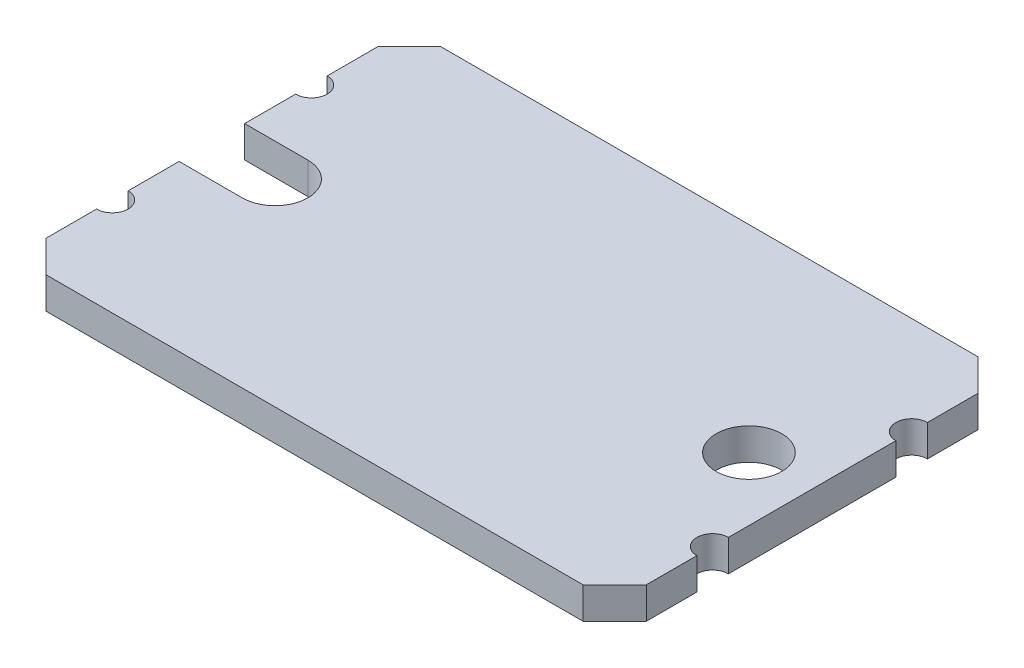
from build123d import *

# Parameters (mm, degrees)
SKETCH1_R      = 2.075
EXTRUDE1_DEPTH = 2


with BuildPart() as part:
    # Sketch1 → Extrude1 (new body)
    with BuildSketch(Plane(origin=(0, 0, 0), x_dir=(1, 0, 0), z_dir=(0, 1, 0))):
        with BuildLine():
            Line((2, 0), (36, 0))
            Line((36, 0), (38, 2))
            Line((38, 2), (38, 5.2))
            ThreePointArc((38, 5.2), (37, 6.2), (38, 7.2))
            Line((38, 7.2), (38, 17.8))
            ThreePointArc((38, 17.8), (37, 18.8), (38, 19.8))
            Line((38, 19.8), (38, 23))
            Line((38, 23), (36, 25))
            Line((36, 25), (2, 25))
            Line((2, 25), (0, 23))
            Line((0, 23), (0, 19.8))
            ThreePointArc((0, 19.8), (1, 18.8), (0, 17.8))
            Line((0, 17.8), (0, 14.575))
            Line((0, 14.575), (4, 14.575))
            ThreePointArc((4, 14.575), (6.075, 12.5), (4, 10.425))
            Line((4, 10.425), (0, 10.425))
            Line((0, 10.425), (0, 7.2))
            ThreePointArc((0, 7.2), (1, 6.2), (0, 5.2))
            Line((0, 5.2), (0, 2))
            Line((0, 2), (2, 0))
        make_face()
        with Locations(Location((34, 12.5, 0), (0, 0, 270))):  # turned: the seam where the file's is
            Circle(SKETCH1_R, mode=Mode.SUBTRACT)
    extrude(amount=EXTRUDE1_DEPTH)


solid = part.part
